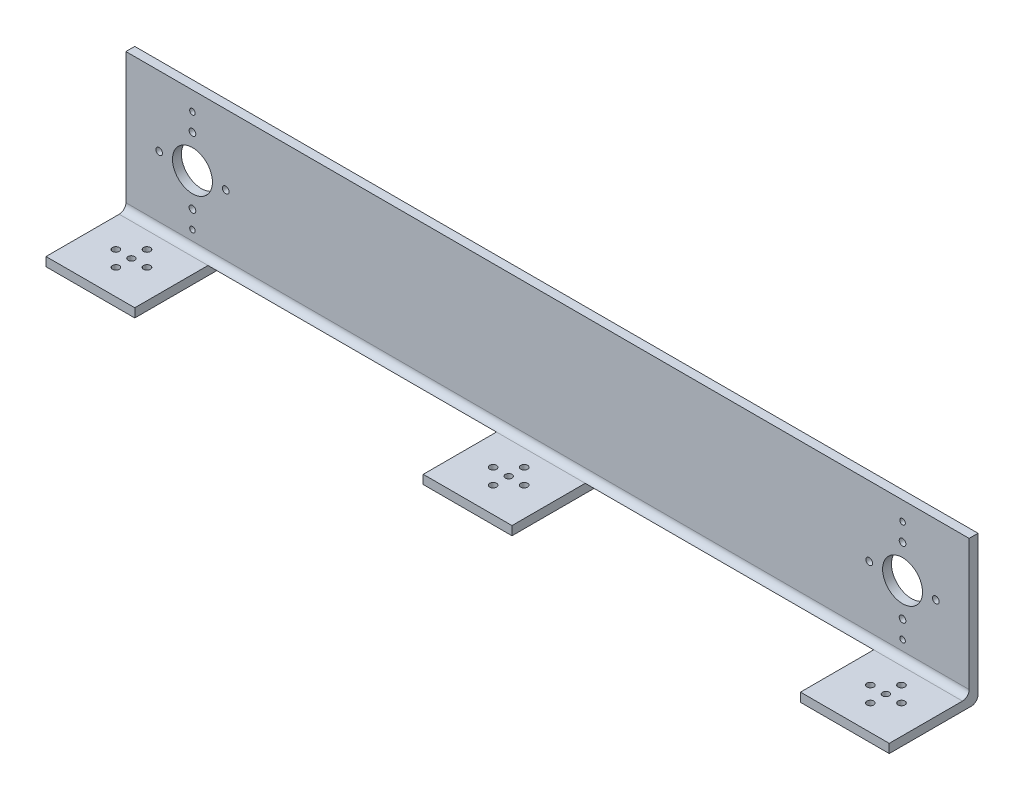
from build123d import *

# Parameters (mm, degrees)
BOSS_EXTRUDE1_DEPTH = 380
FILLET4_R           = 3
HOLE2_D             = 18
HOLE2_DEPTH         = 4
SKETCH18_W          = 130
SKETCH18_H          = 37
CUT_EXTRUDE1_DEPTH  = 4
HOLE5_D             = 3
HOLE5_DEPTH         = 4
HOLE6_D             = 3
HOLE6_DEPTH         = 4
HOLE7_D             = 2.5
HOLE7_DEPTH         = 4
SKETCH27_R          = 1.55
CUT_EXTRUDE3_DEPTH  = 4


with BuildPart() as part:
    # Sketch1 → Boss-Extrude1 (new body)
    with BuildSketch(Plane(origin=(0, 0, 0), x_dir=(0, 0, -1), z_dir=(1, 0, 0))):
        Polygon((-32.21677116, -27.719218501), (7.78322884, -27.719218501), (7.78322884, 38.280781499), (3.78322884, 38.280781499), (3.78322884, -23.719218501), (-32.21677116, -23.719218501), align=None)
    extrude(amount=BOSS_EXTRUDE1_DEPTH)

    # Fillet4
    fillet4_edges = [part.edges().sort_by_distance(p)[0] for p in [
        (190, -23.719218501, -3.78322884),
        (190, -27.719218501, -7.78322884),
    ]]
    fillet(fillet4_edges, radius=FILLET4_R)

    # Hole2
    with Locations(Plane.XY.offset(-3.78322884)):
        with Locations((30, 6.780781499), (350, 6.780781499)):
            Hole(HOLE2_D / 2, depth=HOLE2_DEPTH)

    # Sketch18 → Cut-Extrude1 (cut)
    with BuildSketch(Plane.XZ.offset(27.719218501)):
        with Locations((105, 13.71677116)):
            Rectangle(SKETCH18_W, SKETCH18_H)
        with Locations((275, 13.71677116)):
            Rectangle(SKETCH18_W, SKETCH18_H)
    extrude(amount=-CUT_EXTRUDE1_DEPTH, mode=Mode.SUBTRACT)

    # Hole5
    with Locations(Plane(origin=(360, -27.719218501, 13.71677116), x_dir=(0, 0, -1), z_dir=(0, -1, 0))):
        with Locations((0, 0), (0, -170), (0, -340)):
            Hole(HOLE5_D / 2, depth=HOLE5_DEPTH)

    # Hole6
    with Locations(Plane(origin=(30, 21.780781499, -7.78322884), x_dir=(-1, 0, 0), z_dir=(0, 0, -1))):
        with Locations((0, 0), (15, -15), (0, -30), (-320, -30), (-335, -15), (-320, 0), (-305, -15), (-15, -15)):
            Hole(HOLE6_D / 2, depth=HOLE6_DEPTH)

    # Hole7
    with Locations(Plane(origin=(30, 29.780781499, -7.78322884), x_dir=(-1, 0, 0), z_dir=(0, 0, -1))):
        with Locations((0, 0), (0, -46), (-320, 0), (-320, -46)):
            Hole(HOLE7_D / 2, depth=HOLE7_DEPTH)

    # Sketch27 → Cut-Extrude3 (cut)
    with BuildSketch(Plane(origin=(0, -23.719218501, 0), x_dir=(1, 0, 0), z_dir=(0, 1, 0))):
        with Locations((20, -20.71677116)):
            Circle(SKETCH27_R)
        with Locations((13, -13.71677116)):
            Circle(SKETCH27_R)
        with Locations((20, -6.71677116)):
            Circle(SKETCH27_R)
        with Locations((27, -13.71677116)):
            Circle(SKETCH27_R)
        with Locations((360, -20.71677116)):
            Circle(SKETCH27_R)
        with Locations((353, -13.71677116)):
            Circle(SKETCH27_R)
        with Locations((360, -6.71677116)):
            Circle(SKETCH27_R)
        with Locations((367, -13.71677116)):
            Circle(SKETCH27_R)
        with Locations((190, -20.71677116)):
            Circle(SKETCH27_R)
        with Locations((183, -13.71677116)):
            Circle(SKETCH27_R)
        with Locations((190, -6.71677116)):
            Circle(SKETCH27_R)
        with Locations((197, -13.71677116)):
            Circle(SKETCH27_R)
    extrude(amount=-CUT_EXTRUDE3_DEPTH, mode=Mode.SUBTRACT)


solid = part.part
